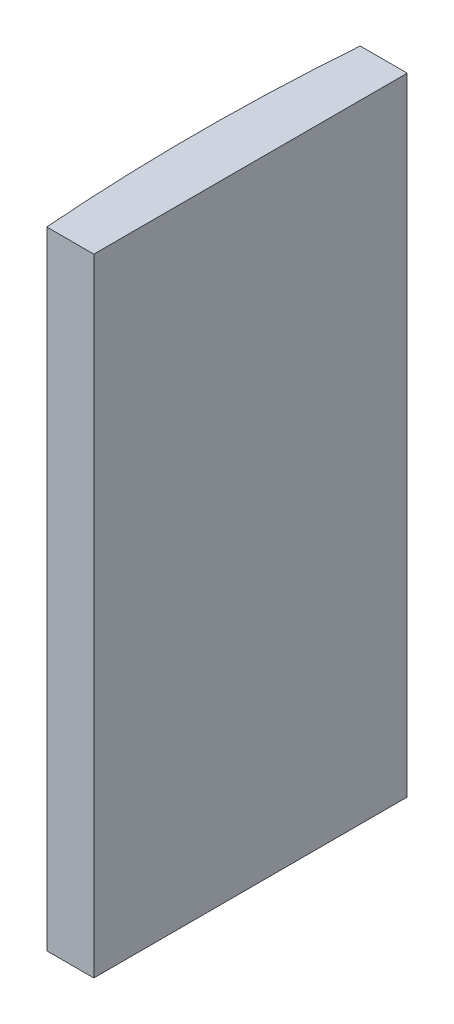
from build123d import *

# Parameters (mm, degrees)
EXTRUDE_1_DEPTH = 40


with BuildPart() as part:
    # 草图1 → 凸台-拉伸1 (new body)
    with BuildSketch(Plane(origin=(0, 0, 0), x_dir=(1, 0, 0), z_dir=(0, 1, 0))):
        with BuildLine():
            Line((-124.507367811, 10), (-121.504795665, 10))
            Line((-121.504795665, 10), (-121.504795665, -10))
            Line((-121.504795665, -10), (-124.507367811, -10))
            ThreePointArc((-124.507367811, -10), (-124.894795665, 0), (-124.507367811, 10))
        make_face()
    extrude(amount=EXTRUDE_1_DEPTH)


solid = part.part
